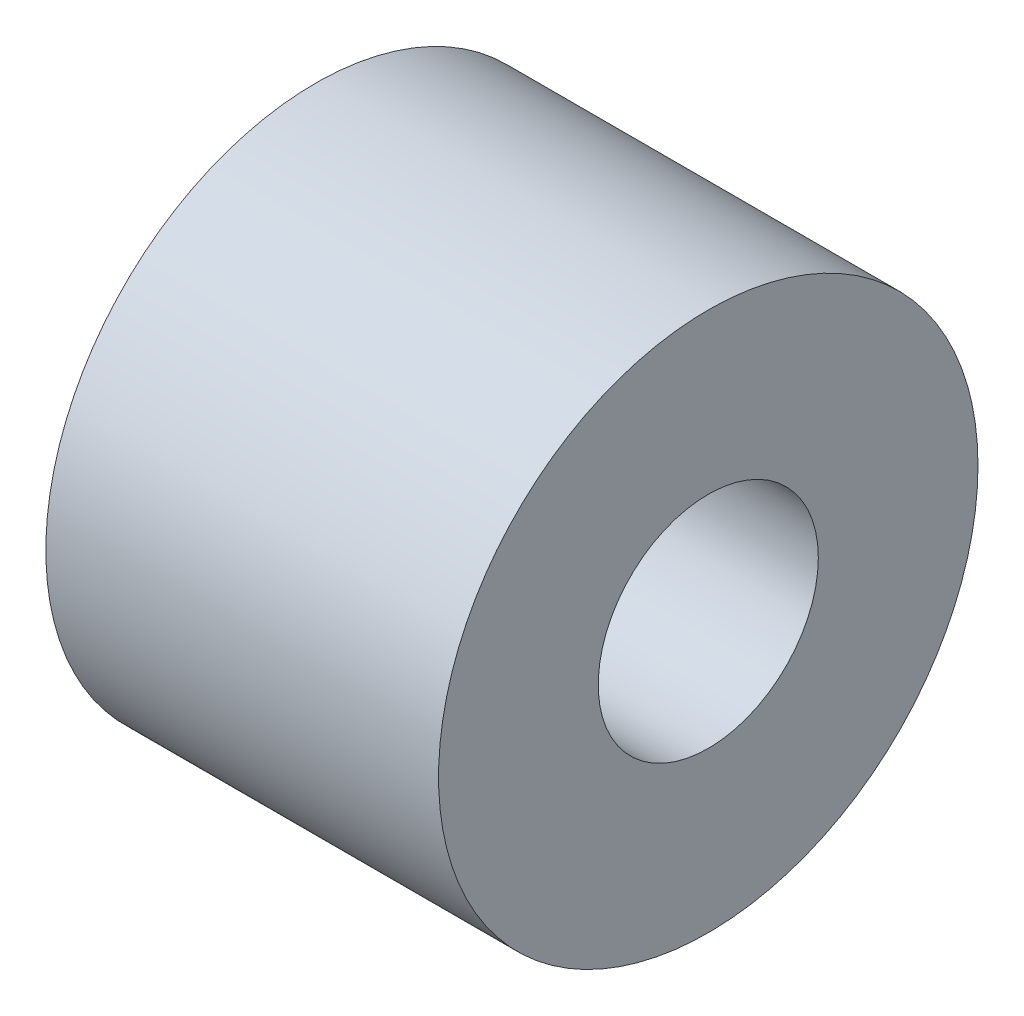
from build123d import *

# Parameters (mm, degrees)
SKETCH1_R           = 6.25
SKETCH1_R_2         = 2.55
BOSS_EXTRUDE1_DEPTH = 4.55


with BuildPart() as part:
    # Sketch1 → Boss-Extrude1 (new body, symmetric)
    with BuildSketch(Plane(origin=(0, 0, 0), x_dir=(0, 0, -1), z_dir=(1, 0, 0))):
        Circle(SKETCH1_R)
        Circle(SKETCH1_R_2, mode=Mode.SUBTRACT)
    extrude(amount=BOSS_EXTRUDE1_DEPTH, both=True)


solid = part.part
